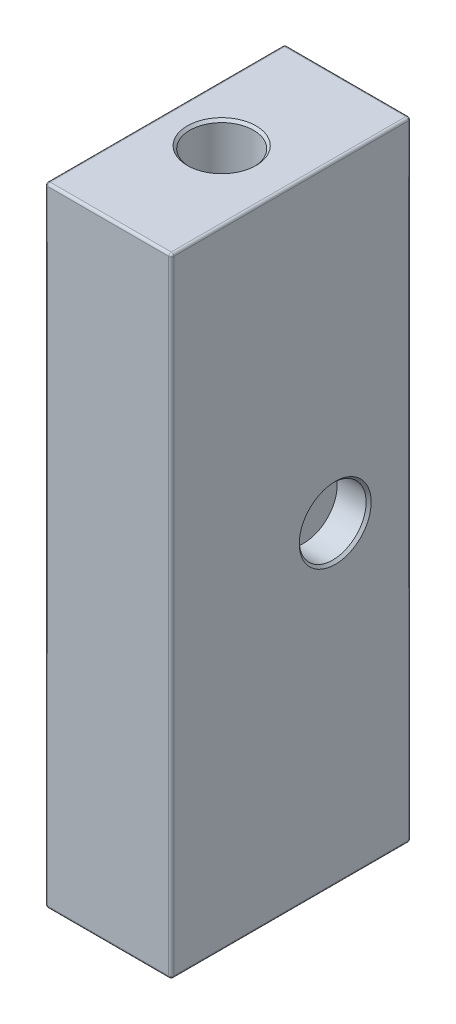
from build123d import *

# Parameters (mm, degrees)
SKETCH1_W           = 10
SKETCH1_H           = 19
SKETCH1_R           = 2.525
BOSS_EXTRUDE1_DEPTH = 24.9
SKETCH2_R           = 2.65
CUT_EXTRUDE1_DEPTH  = 2.5
FILLET1_R           = 0.2
CHAMFER1_SIZE       = 0.2


with BuildPart() as part:
    # Sketch1 → Boss-Extrude1 (new body, symmetric)
    with BuildSketch(Plane(origin=(0, 0, 0), x_dir=(1, 0, 0), z_dir=(0, 1, 0))):
        Rectangle(SKETCH1_W, SKETCH1_H)
        with Locations((-0.5, 0)):
            Circle(SKETCH1_R, mode=Mode.SUBTRACT)
    extrude(amount=BOSS_EXTRUDE1_DEPTH, both=True)

    # Sketch2 → Cut-Extrude1 (cut)
    with BuildSketch(Plane(origin=(5, 0, 0), x_dir=(0, 0, -1), z_dir=(1, 0, 0))):
        with Locations((3.5, 0)):
            Circle(SKETCH2_R)
    extrude(amount=-CUT_EXTRUDE1_DEPTH, mode=Mode.SUBTRACT)

    # Fillet1
    fillet1_edges = [part.edges().sort_by_distance(p)[0] for p in [
        (5, 24.9, 0),
        (0, 24.9, -9.5),
        (-5, 24.9, 0),
        (0, -24.9, -9.5),
        (5, -24.9, 0),
        (0, -24.9, 9.5),
        (-5, -24.9, 0),
        (-5, 0, -9.5),
        (5, 0, -9.5),
        (5, 0, 9.5),
        (-5, 0, 9.5),
        (0, 24.9, 9.5),
    ]]
    fillet(fillet1_edges, radius=FILLET1_R)

    # Chamfer1
    chamfer1_edges = [part.edges().sort_by_distance(p)[0] for p in [
        (-3.025, 24.9, 0),
        (5, 0, -0.85),
    ]]
    chamfer(chamfer1_edges, length=CHAMFER1_SIZE)


solid = part.part
